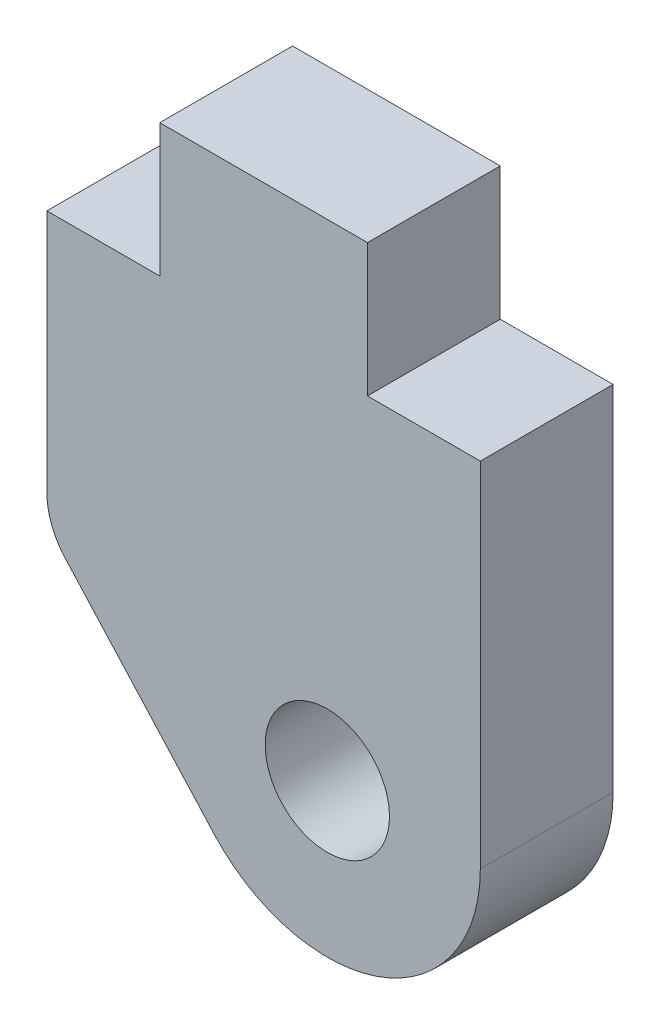
from build123d import *

# Parameters (mm, degrees)
SKETCH1_R           = 1.4859
BOSS_EXTRUDE1_DEPTH = 3.175


with BuildPart() as part:
    # Sketch1 → Boss-Extrude1 (new body)
    with BuildSketch(Plane.XY):
        with BuildLine():
            Line((-4.744382059, -2.509411554), (-1.186842353, -6.436927856))
            ThreePointArc((-1.186842353, -6.436927856), (2.839838282, -7.394162612), (5.1816, -3.98145))
            Line((5.1816, -3.98145), (5.1816, 4.46405))
            Line((5.1816, 4.46405), (2.48285, 4.46405))
            Line((2.48285, 4.46405), (2.48285, 7.63905))
            Line((2.48285, 7.63905), (-2.48285, 7.63905))
            Line((-2.48285, 7.63905), (-2.48285, 4.46405))
            Line((-2.48285, 4.46405), (-5.1816, 4.46405))
            Line((-5.1816, 4.46405), (-5.1816, -1.375458239))
            ThreePointArc((-5.1816, -1.375458239), (-5.068509644, -1.983119668), (-4.744382059, -2.509411554))
        make_face()
        with Locations((1.524, -3.98145)):
            Circle(SKETCH1_R, mode=Mode.SUBTRACT)
    extrude(amount=BOSS_EXTRUDE1_DEPTH)


solid = part.part
